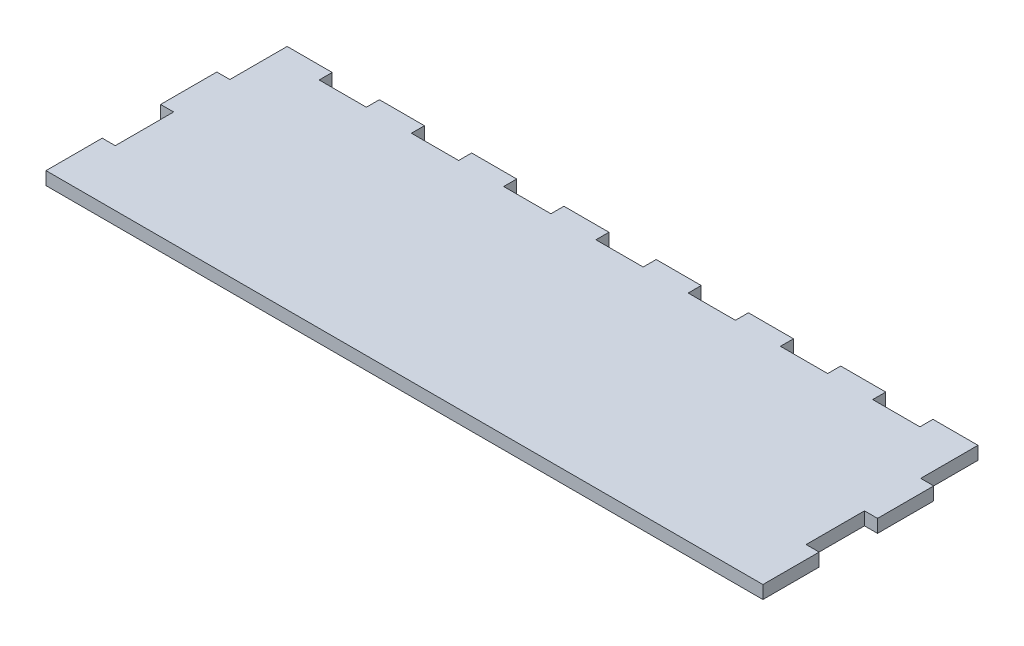
from build123d import *

# Parameters (mm, degrees)
BOSS_EXTRUDE1_DEPTH = 6


with BuildPart() as part:
    # Sketch1 → Boss-Extrude1 (new body)
    with BuildSketch(Plane.XZ):
        Polygon((48.466666667, 6), (48.466666667, 0), (69.2, 0), (69.2, 6), (90.933333333, 6), (90.933333333, 0), (111.666666667, 0), (111.666666667, 6), (133.4, 6), (133.4, 0), (154.133333333, 0), (154.133333333, 6), (175.866666667, 6), (175.866666667, 0), (196.6, 0), (196.6, 6), (218.333333333, 6), (218.333333333, 0), (239.066666667, 0), (239.066666667, 6), (260.8, 6), (260.8, 0), (281.533333333, 0), (281.533333333, 6), (303.266666667, 6), (303.266666667, 0), (324, 0), (324, 26.375), (330, 26.375), (330, 52.25), (324, 52.25), (324, 79.125), (330, 79.125), (330, 105), (0, 105), (0, 79.125), (6, 79.125), (6, 52.25), (0, 52.25), (0, 26.375), (6, 26.375), (6, 0), (26.733333333, 0), (26.733333333, 6), align=None)
    extrude(amount=-BOSS_EXTRUDE1_DEPTH)


solid = part.part
